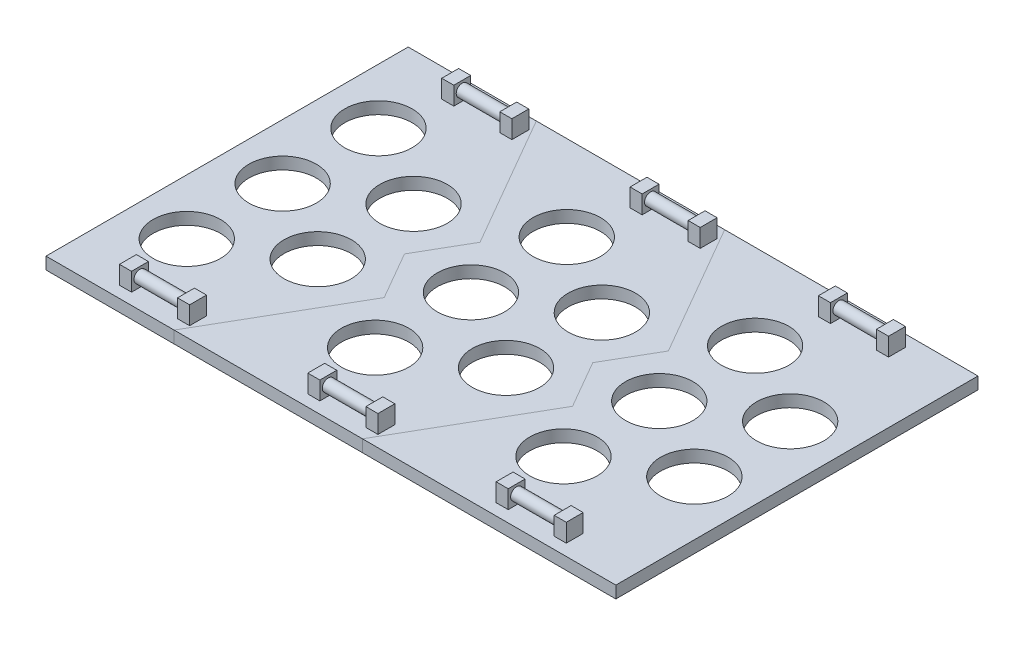
from build123d import *

# Parameters (mm, degrees)
SKETCH1_W                 = 236
SKETCH1_H                 = 75
BOSS_EXTRUDE1_DEPTH       = 2.5
SKETCH4_R                 = 13.97
CUT_EXTRUDE1_DEPTH        = 10.4
LPATTERN1_COUNT           = 3
LPATTERN1_PITCH           = 78
SKETCH10_W                = 5
SKETCH10_H                = 7
BOSS_EXTRUDE2_DEPTH       = 7.5
SKETCH11_R                = 2.5
BOSS_EXTRUDE3_DEPTH       = 19.05
LPATTERN2_COUNT           = 3
LPATTERN2_PITCH           = 78
LPATTERN2_COPY_1_SKETCH_W = 5
LPATTERN2_COPY_1_SKETCH_H = 7
LPATTERN2_COPY_1_DEPTH    = 7.5
LPATTERN2_COPY_2_SKETCH_W = 5
LPATTERN2_COPY_2_SKETCH_H = 7
LPATTERN2_COPY_2_DEPTH    = 7.5
LPATTERN2_COPY_3_SKETCH_R = 2.5
LPATTERN2_COPY_3_DEPTH    = 19.05
LPATTERN2_COPY_4_SKETCH_R = 2.5
LPATTERN2_COPY_4_DEPTH    = 19.05
SPLIT1_SURFACE_1_1_BACK   = 280.915
SPLIT1_SURFACE_1_1_DEPTH  = 561.83
SPLIT1_SURFACE_1_2_BACK   = 280.915
SPLIT1_SURFACE_1_2_DEPTH  = 561.83
SPLIT1_SURFACE_2_3_BACK   = 280.915
SPLIT1_SURFACE_2_3_DEPTH  = 561.83
SPLIT1_SURFACE_2_4_BACK   = 280.915
SPLIT1_SURFACE_2_4_DEPTH  = 561.83


with BuildPart() as part:
    # Sketch1 → Boss-Extrude1 (new, symmetric)
    with BuildSketch(Plane(origin=(0, 0, 0), x_dir=(1, 0, 0), z_dir=(0, 1, 0))):
        with Locations((0, -37.5)):
            Rectangle(SKETCH1_W, SKETCH1_H)
        with Locations((0, 37.5)):
            Rectangle(SKETCH1_W, SKETCH1_H)
    extrude(amount=BOSS_EXTRUDE1_DEPTH, both=True)

    # Sketch4 → Cut-Extrude1 (cut)
    with BuildSketch(Plane(origin=(0, 2.5, 0), x_dir=(1, 0, 0), z_dir=(0, 1, 0))):
        with Locations(Location((-95, 0, 0), (0, 0, 270))):
            Circle(SKETCH4_R)
        with Locations(Location((-95, -39.6875, 0), (0, 0, 270))):
            Circle(SKETCH4_R)
        with Locations(Location((-95, 39.6875, 0), (0, 0, 270))):
            Circle(SKETCH4_R)
        with Locations(Location((-60.629616787, 19.84375, 0), (0, 0, 270))):
            Circle(SKETCH4_R)
        with Locations(Location((-60.629616787, -19.84375, 0), (0, 0, 270))):
            Circle(SKETCH4_R)
    cut_extrude1 = extrude(amount=-CUT_EXTRUDE1_DEPTH, mode=Mode.SUBTRACT)

    # LPattern1: Cut-Extrude1 ×3
    with Locations(*[(i * LPATTERN1_PITCH, 0, 0) for i in range(1, LPATTERN1_COUNT)]):
        add(cut_extrude1, mode=Mode.SUBTRACT)

    # Sketch10 → Boss-Extrude2 (add)
    with BuildSketch(Plane(origin=(0, 2.5, 0), x_dir=(1, 0, 0), z_dir=(0, 1, 0))):
        with Locations((-89.839808394, -66.7375)):
            Rectangle(SKETCH10_W, SKETCH10_H)
        with Locations((-65.789808394, -66.7375)):
            Rectangle(SKETCH10_W, SKETCH10_H)
    boss_extrude2 = extrude(amount=BOSS_EXTRUDE2_DEPTH)

    # Sketch11 → Boss-Extrude3 (add)
    with BuildSketch(Plane(origin=(-87.339808394, 0, 0), x_dir=(0, 0, -1), z_dir=(1, 0, 0))):
        with Locations(Location((-66.7375, 6.5, 0), (0, 0, 180))):
            Circle(SKETCH11_R)
    boss_extrude3 = extrude(amount=BOSS_EXTRUDE3_DEPTH)

    # Mirror1: Boss-Extrude2, Boss-Extrude3 across plane
    add(boss_extrude2.mirror(Plane.XY))
    add(boss_extrude3.mirror(Plane.XY))

    # LPattern2: Boss-Extrude2, Boss-Extrude3 ×3
    with Locations(*[(i * LPATTERN2_PITCH, 0, 0) for i in range(1, LPATTERN2_COUNT)]):
        add(boss_extrude2)
        add(boss_extrude3)

    # LPattern2 copy 1 sketch → LPattern2 copy 1 (add)
    with BuildSketch(Plane(origin=(78, 2.5, 0), x_dir=(1, 0, 0), z_dir=(0, 1, 0))):
        with Locations((-89.839808394, 66.7375)):
            Rectangle(LPATTERN2_COPY_1_SKETCH_W, LPATTERN2_COPY_1_SKETCH_H)
        with Locations((-65.789808394, 66.7375)):
            Rectangle(LPATTERN2_COPY_1_SKETCH_W, LPATTERN2_COPY_1_SKETCH_H)
    extrude(amount=LPATTERN2_COPY_1_DEPTH)

    # LPattern2 copy 2 sketch → LPattern2 copy 2 (add)
    with BuildSketch(Plane(origin=(156, 2.5, 0), x_dir=(1, 0, 0), z_dir=(0, 1, 0))):
        with Locations((-89.839808394, 66.7375)):
            Rectangle(LPATTERN2_COPY_2_SKETCH_W, LPATTERN2_COPY_2_SKETCH_H)
        with Locations((-65.789808394, 66.7375)):
            Rectangle(LPATTERN2_COPY_2_SKETCH_W, LPATTERN2_COPY_2_SKETCH_H)
    extrude(amount=LPATTERN2_COPY_2_DEPTH)

    # LPattern2 copy 3 sketch → LPattern2 copy 3 (add)
    with BuildSketch(Plane(origin=(-9.339808394, 0, 0), x_dir=(0, 0, 1), z_dir=(1, 0, 0))):
        with Locations((-66.7375, -6.5)):
            Circle(LPATTERN2_COPY_3_SKETCH_R)
    extrude(amount=LPATTERN2_COPY_3_DEPTH)

    # LPattern2 copy 4 sketch → LPattern2 copy 4 (add)
    with BuildSketch(Plane(origin=(68.660191606, 0, 0), x_dir=(0, 0, 1), z_dir=(1, 0, 0))):
        with Locations((-66.7375, -6.5)):
            Circle(LPATTERN2_COPY_4_SKETCH_R)
    extrude(amount=LPATTERN2_COPY_4_DEPTH)


with BuildPart() as body_2:
    # Split1: the piece behind the surface
    add(part.part)
    # Split1 surface 1: a surface, the sketch's curves swept straight by 561.83 mm
    with BuildLine(Plane(origin=(0, 2.5, 0), x_dir=(1, 0, 0), z_dir=(0, 1, 0)).offset(-SPLIT1_SURFACE_1_1_BACK), mode=Mode.PRIVATE) as split1_surface_1_1_path:
        Line((-64.930886977, -75), (-35.53844397, -24.090795355))
        Line((-35.53844397, -24.090795355), (-33.086411192, -19.84375))
        Line((-33.086411192, -19.84375), (-39.731799052, -8.333600589))
        Line((-39.731799052, -8.333600589), (-44.543205596, 0))
        Line((-44.543205596, 0), (-39.97221259, 7.917192126))
        Line((-39.97221259, 7.917192126), (-33.086411192, 19.84375))
        Line((-33.086411192, 19.84375), (-39.97221259, 31.770307874))
        Line((-39.97221259, 31.770307874), (-64.930886977, 75))
    split1_surface_1_1 = Shell.extrude(split1_surface_1_1_path.wire(), (0 * SPLIT1_SURFACE_1_1_DEPTH, 1 * SPLIT1_SURFACE_1_1_DEPTH, 0 * SPLIT1_SURFACE_1_1_DEPTH))
    split(bisect_by=split1_surface_1_1, keep=Keep.BOTTOM)


with BuildPart() as part_1:
    add(part.part)

    # Split1: split by a surface, the side it looks to stays
    # Split1 surface 1: a surface, the sketch's curves swept straight by 561.83 mm
    with BuildLine(Plane(origin=(0, 2.5, 0), x_dir=(1, 0, 0), z_dir=(0, 1, 0)).offset(-SPLIT1_SURFACE_1_2_BACK), mode=Mode.PRIVATE) as split1_surface_1_2_path:
        Line((-64.930886977, -75), (-35.53844397, -24.090795355))
        Line((-35.53844397, -24.090795355), (-33.086411192, -19.84375))
        Line((-33.086411192, -19.84375), (-39.731799052, -8.333600589))
        Line((-39.731799052, -8.333600589), (-44.543205596, 0))
        Line((-44.543205596, 0), (-39.97221259, 7.917192126))
        Line((-39.97221259, 7.917192126), (-33.086411192, 19.84375))
        Line((-33.086411192, 19.84375), (-39.97221259, 31.770307874))
        Line((-39.97221259, 31.770307874), (-64.930886977, 75))
    split1_surface_1_2 = Shell.extrude(split1_surface_1_2_path.wire(), (0 * SPLIT1_SURFACE_1_2_DEPTH, 1 * SPLIT1_SURFACE_1_2_DEPTH, 0 * SPLIT1_SURFACE_1_2_DEPTH))
    split(bisect_by=split1_surface_1_2, keep=Keep.TOP)


with BuildPart() as body_3:
    # Split1 2 body 2: the piece behind the surface
    add(body_2.part)
    # Split1 surface 2: a surface, the sketch's curves swept straight by 561.83 mm
    with BuildLine(Plane(origin=(0, 2.5, 0), x_dir=(1, 0, 0), z_dir=(0, 1, 0)).offset(-SPLIT1_SURFACE_2_3_BACK), mode=Mode.PRIVATE) as split1_surface_2_3_path:
        Line((13.069113023, 75), (41.969616323, 24.942859921))
        Line((41.969616323, 24.942859921), (44.913588808, 19.84375))
        Line((44.913588808, 19.84375), (38.02778741, 7.917192126))
        Line((38.02778741, 7.917192126), (33.456794404, 0))
        Line((33.456794404, 0), (43.527048724, -17.442192126))
        Line((43.527048724, -17.442192126), (44.913588808, -19.84375))
        Line((44.913588808, -19.84375), (38.02778741, -31.770307874))
        Line((38.02778741, -31.770307874), (13.069113023, -75))
    split1_surface_2_3 = Shell.extrude(split1_surface_2_3_path.wire(), (0 * SPLIT1_SURFACE_2_3_DEPTH, 1 * SPLIT1_SURFACE_2_3_DEPTH, 0 * SPLIT1_SURFACE_2_3_DEPTH))
    split(bisect_by=split1_surface_2_3, keep=Keep.BOTTOM)


with BuildPart() as body_2_1:
    add(body_2.part)

    # Split1 2 body 2: split by a surface, the side it looks to stays
    # Split1 surface 2: a surface, the sketch's curves swept straight by 561.83 mm
    with BuildLine(Plane(origin=(0, 2.5, 0), x_dir=(1, 0, 0), z_dir=(0, 1, 0)).offset(-SPLIT1_SURFACE_2_4_BACK), mode=Mode.PRIVATE) as split1_surface_2_4_path:
        Line((13.069113023, 75), (41.969616323, 24.942859921))
        Line((41.969616323, 24.942859921), (44.913588808, 19.84375))
        Line((44.913588808, 19.84375), (38.02778741, 7.917192126))
        Line((38.02778741, 7.917192126), (33.456794404, 0))
        Line((33.456794404, 0), (43.527048724, -17.442192126))
        Line((43.527048724, -17.442192126), (44.913588808, -19.84375))
        Line((44.913588808, -19.84375), (38.02778741, -31.770307874))
        Line((38.02778741, -31.770307874), (13.069113023, -75))
    split1_surface_2_4 = Shell.extrude(split1_surface_2_4_path.wire(), (0 * SPLIT1_SURFACE_2_4_DEPTH, 1 * SPLIT1_SURFACE_2_4_DEPTH, 0 * SPLIT1_SURFACE_2_4_DEPTH))
    split(bisect_by=split1_surface_2_4, keep=Keep.TOP)


solid = Compound([part_1.part, body_3.part, body_2_1.part])
